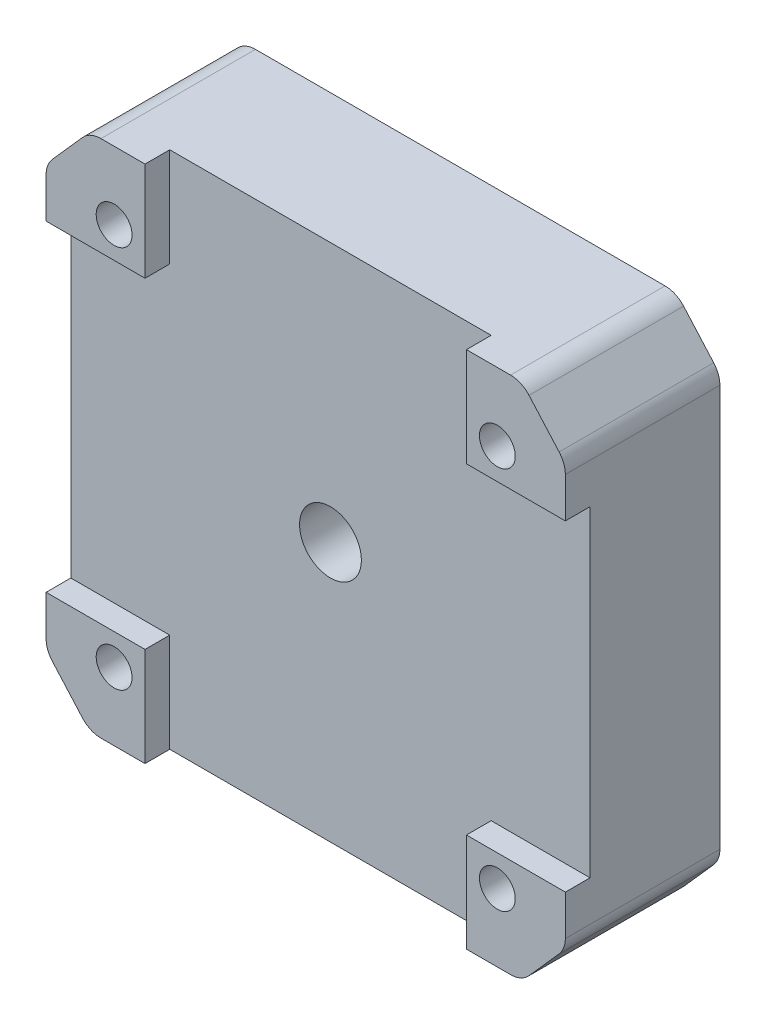
from build123d import *

# Parameters (mm, degrees)
BOSS_EXTRUDE1_DEPTH                                = 12.5
SKETCH2_W                                          = 2
SKETCH2_H                                          = 26
CUT_EXTRUDE1_DEPTH                                 = 43
SKETCH3_W                                          = 26
SKETCH3_H                                          = 2
CUT_EXTRUDE2_DEPTH                                 = 43
SKETCH4_R                                          = 3.25
CUT_EXTRUDE3_DEPTH                                 = 3
SKETCH5_R                                          = 2.5
CUT_EXTRUDE4_DEPTH                                 = 11.5
CBORE_FOR_M2_5_PAN_HEAD_MACHINE_SCREW1_D           = 2.9
CBORE_FOR_M2_5_PAN_HEAD_MACHINE_SCREW1_CBORE_D     = 6
CBORE_FOR_M2_5_PAN_HEAD_MACHINE_SCREW1_CBORE_DEPTH = 2.1
FILLET1_R                                          = 2


with BuildPart() as part:
    # Sketch1 → Boss-Extrude1 (new body)
    with BuildSketch(Plane.XY):
        Polygon((-17.465670258, 21), (-21, 17.012864847), (-21, -17.012864847), (-17.465670258, -21), (17.465670258, -21), (21, -17.012864847), (21, 17.012864847), (17.465670258, 21), align=None)
    extrude(amount=BOSS_EXTRUDE1_DEPTH)

    # Sketch2 → Cut-Extrude1 (cut, through all)
    with BuildSketch(Plane(origin=(21, 0, 0), x_dir=(0, 0, -1), z_dir=(1, 0, 0))):
        with Locations((-11.5, 0)):
            Rectangle(SKETCH2_W, SKETCH2_H)
    extrude(amount=-CUT_EXTRUDE1_DEPTH, mode=Mode.SUBTRACT)

    # Sketch3 → Cut-Extrude2 (cut, through all)
    with BuildSketch(Plane.XZ.offset(21)):
        with Locations((0, 11.5)):
            Rectangle(SKETCH3_W, SKETCH3_H)
    extrude(amount=-CUT_EXTRUDE2_DEPTH, mode=Mode.SUBTRACT)

    # Sketch4 → Cut-Extrude3 (cut)
    with BuildSketch(Plane(origin=(0, 0, 0), x_dir=(-1, 0, 0), z_dir=(0, 0, -1))):
        Circle(SKETCH4_R)
    extrude(amount=-CUT_EXTRUDE3_DEPTH, mode=Mode.SUBTRACT)

    # Sketch5 → Cut-Extrude4 (cut, through all)
    with BuildSketch(Plane.XY.offset(10.5)):
        Circle(SKETCH5_R)
    extrude(amount=-CUT_EXTRUDE4_DEPTH, mode=Mode.SUBTRACT)

    # CBORE for M2.5 Pan Head Machine Screw1 (through all)
    with Locations(Plane(origin=(0, 0, 0), x_dir=(-1, 0, 0), z_dir=(0, 0, -1))):
        with Locations((-15.5, 15.5), (15.5, 15.5), (15.5, -15.5), (-15.5, -15.5)):
            CounterBoreHole(CBORE_FOR_M2_5_PAN_HEAD_MACHINE_SCREW1_D / 2, CBORE_FOR_M2_5_PAN_HEAD_MACHINE_SCREW1_CBORE_D / 2, CBORE_FOR_M2_5_PAN_HEAD_MACHINE_SCREW1_CBORE_DEPTH)

    # Fillet1
    fillet1_edges = [part.edges().sort_by_distance(p)[0] for p in [
        (17.465670258, 21, 6.25),
        (21, 17.012864847, 6.25),
        (21, -17.012864847, 6.25),
        (17.465670258, -21, 6.25),
        (-17.465670258, -21, 6.25),
        (-21, -17.012864847, 6.25),
        (-21, 17.012864847, 6.25),
        (-17.465670258, 21, 6.25),
    ]]
    fillet(fillet1_edges, radius=FILLET1_R)


solid = part.part
